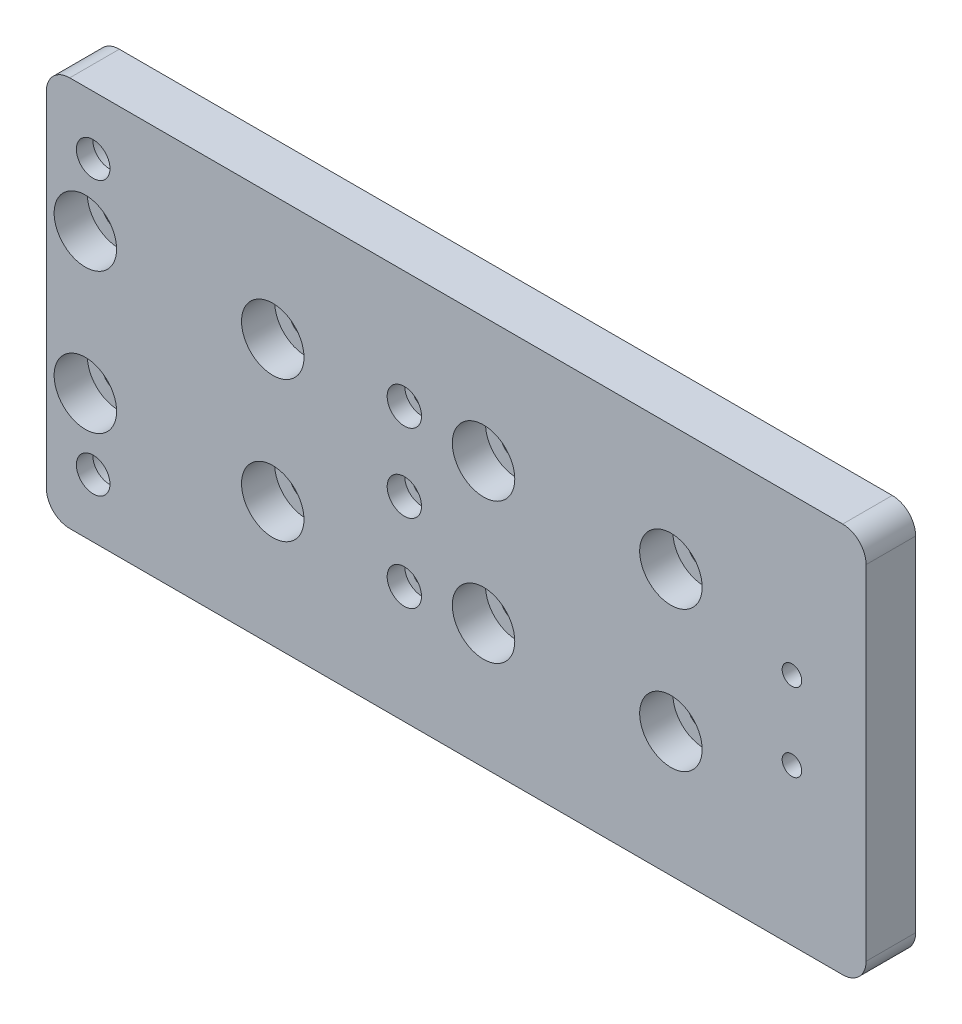
from build123d import *

# Parameters (mm, degrees)
ESBO_O1_W                                            = 105
ESBO_O1_H                                            = 50
RESSALTO_EXTRUS_O1_DEPTH                             = 6.35
FURO_DE_DI_METRO_2_5_2_5_1_D                         = 2.5
FURO_DE_DI_METRO_2_5_2_5_1_DEPTH                     = 6.35
REBAIXO_PARA_PARAFUSO_DE_M_QUINA_DE_CABE_D           = 2.2
REBAIXO_PARA_PARAFUSO_DE_M_QUINA_DE_CABE_DEPTH       = 6.35
REBAIXO_PARA_PARAFUSO_DE_M_QUINA_DE_CABE_CBORE_D     = 4.4
REBAIXO_PARA_PARAFUSO_DE_M_QUINA_DE_CABE_CBORE_DEPTH = 2.25
REBAIXO_PARA_PARAFUSO_DE_M_QUINA_DE_2_D              = 4.3
REBAIXO_PARA_PARAFUSO_DE_M_QUINA_DE_2_CBORE_D        = 8
REBAIXO_PARA_PARAFUSO_DE_M_QUINA_DE_2_CBORE_DEPTH    = 4.25
REBAIXO_PARA_PARAFUSO_DE_M_QUINA_DE_3_D              = 4.3
REBAIXO_PARA_PARAFUSO_DE_M_QUINA_DE_3_DEPTH          = 6.35
REBAIXO_PARA_PARAFUSO_DE_M_QUINA_DE_3_CBORE_D        = 8
REBAIXO_PARA_PARAFUSO_DE_M_QUINA_DE_3_CBORE_DEPTH    = 4.25
FILETE1_R                                            = 3
ESBO_O11_R                                           = 4
RESSALTO_EXTRUS_O2_DEPTH                             = 6.35


with BuildPart() as part:
    # Esboço1 → Ressalto-extrusão1 (new body)
    with BuildSketch(Plane.XY.offset(6.35)):
        with Locations((52.5, 12)):
            Rectangle(ESBO_O1_W, ESBO_O1_H)
    extrude(amount=-RESSALTO_EXTRUS_O1_DEPTH)

    # Furo de diâmetro Ø2.5 (2.5)1
    with Locations(Plane(origin=(0, 0, 0), x_dir=(-1, 0, 0), z_dir=(0, 0, -1))):
        with Locations((-95.5, 17), (-95.5, 7)):
            Hole(FURO_DE_DI_METRO_2_5_2_5_1_D / 2, depth=FURO_DE_DI_METRO_2_5_2_5_1_DEPTH)

    # Rebaixo para parafuso de m_quina de cabe
    with Locations(Plane.XY.offset(6.35)):
        with Locations((45.856, 22), (45.856, 2), (45.856, 12)):
            CounterBoreHole(REBAIXO_PARA_PARAFUSO_DE_M_QUINA_DE_CABE_D / 2, REBAIXO_PARA_PARAFUSO_DE_M_QUINA_DE_CABE_CBORE_D / 2, REBAIXO_PARA_PARAFUSO_DE_M_QUINA_DE_CABE_CBORE_DEPTH, depth=REBAIXO_PARA_PARAFUSO_DE_M_QUINA_DE_CABE_DEPTH)

    # Rebaixo para parafuso de m_quina de  2 (through all)
    with Locations(Plane(origin=(0, 0, 0), x_dir=(-1, 0, 0), z_dir=(0, 0, -1))):
        with Locations((-6, -5.5), (-6, 29.5), (-71, -1.5), (-71, 25.5)):
            CounterBoreHole(REBAIXO_PARA_PARAFUSO_DE_M_QUINA_DE_2_D / 2, REBAIXO_PARA_PARAFUSO_DE_M_QUINA_DE_2_CBORE_D / 2, REBAIXO_PARA_PARAFUSO_DE_M_QUINA_DE_2_CBORE_DEPTH)

    # Rebaixo para parafuso de m_quina de  3
    with Locations(Plane.XY.offset(6.35)):
        with Locations((5, 21), (5, 3), (29, 3), (29, 21), (56, 3), (56, 21), (80, 21), (80, 3)):
            CounterBoreHole(REBAIXO_PARA_PARAFUSO_DE_M_QUINA_DE_3_D / 2, REBAIXO_PARA_PARAFUSO_DE_M_QUINA_DE_3_CBORE_D / 2, REBAIXO_PARA_PARAFUSO_DE_M_QUINA_DE_3_CBORE_DEPTH, depth=REBAIXO_PARA_PARAFUSO_DE_M_QUINA_DE_3_DEPTH)

    # Filete1
    filete1_edges = [part.edges().sort_by_distance(p)[0] for p in [
        (105, 37, 3.175),
        (105, -13, 3.175),
        (0, -13, 3.175),
        (0, 37, 3.175),
    ]]
    fillet(filete1_edges, radius=FILETE1_R)

    # Esboço11 → Ressalto-extrusão2 (add)
    with BuildSketch(Plane(origin=(0, 0, 0), x_dir=(-1, 0, 0), z_dir=(0, 0, -1))):
        with Locations((-71, -1.5)):
            Circle(ESBO_O11_R)
        with Locations((-71, 25.5)):
            Circle(ESBO_O11_R)
    extrude(amount=-RESSALTO_EXTRUS_O2_DEPTH)


solid = part.part
